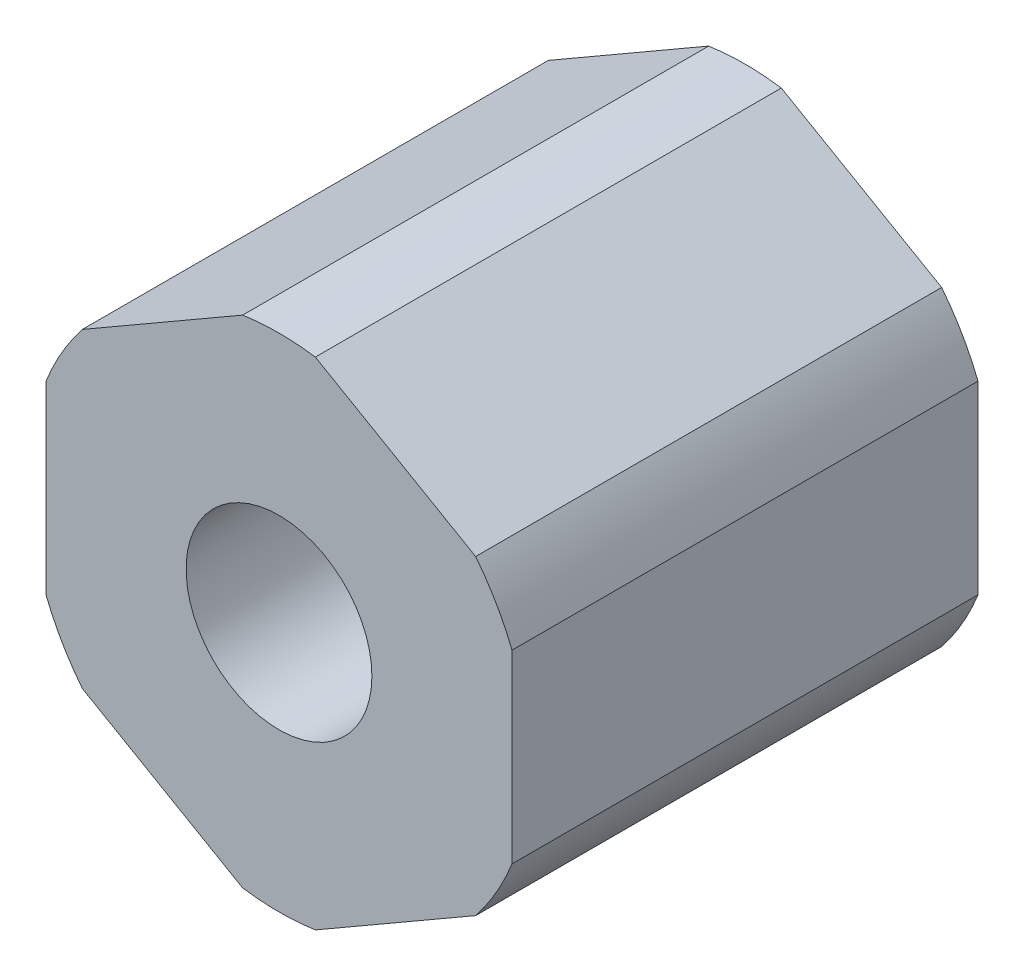
from build123d import *

# Parameters (mm, degrees)
SKETCH1_R               = 4.7625
BASIC_ROD_DEPTH         = 4.7625
BASIC_ROD_DEPTH_BACK    = 4.7625
THEX_DEPTH              = 4.7625
SKETCH2_R               = 1.89865
INTERNAL_CUT_DEPTH      = 5.7625
INTERNAL_CUT_DEPTH_BACK = 5.7625


with BuildPart() as part:
    # Sketch1 → Basic Rod (new body, two sides)
    with BuildSketch(Plane.XY) as basic_rod_sk:
        Circle(SKETCH1_R)
    extrude(amount=BASIC_ROD_DEPTH)
    extrude(basic_rod_sk.sketch, amount=-BASIC_ROD_DEPTH_BACK)

    # Sketch8 → THex (add, symmetric)
    with BuildSketch(Plane.XY):
        with BuildLine():
            Line((-0.742977689, 5.070302945), (-4.019522311, 3.178589026))
            ThreePointArc((-4.019522311, 3.178589026), (-4.43790388, 2.562225), (-4.7625, 1.891713919))
            Line((-4.7625, 1.891713919), (-4.7625, -1.891713919))
            ThreePointArc((-4.7625, -1.891713919), (-4.43790388, -2.562225), (-4.019522311, -3.178589026))
            Line((-4.019522311, -3.178589026), (-0.742977689, -5.070302945))
            ThreePointArc((-0.742977689, -5.070302945), (0, -5.12445), (0.742977689, -5.070302945))
            Line((0.742977689, -5.070302945), (4.019522311, -3.178589026))
            ThreePointArc((4.019522311, -3.178589026), (4.43790388, -2.562225), (4.7625, -1.891713919))
            Line((4.7625, -1.891713919), (4.7625, 1.891713919))
            ThreePointArc((4.7625, 1.891713919), (4.43790388, 2.562225), (4.019522311, 3.178589026))
            Line((4.019522311, 3.178589026), (0.742977689, 5.070302945))
            ThreePointArc((0.742977689, 5.070302945), (0, 5.12445), (-0.742977689, 5.070302945))
        make_face()
    extrude(amount=THEX_DEPTH, both=True)

    # Sketch2 → Internal Cut (cut, two sides)
    with BuildSketch(Plane.XY) as internal_cut_sk:
        Circle(SKETCH2_R)
    extrude(amount=INTERNAL_CUT_DEPTH, mode=Mode.SUBTRACT)
    extrude(internal_cut_sk.sketch, amount=-INTERNAL_CUT_DEPTH_BACK, mode=Mode.SUBTRACT)


solid = part.part
